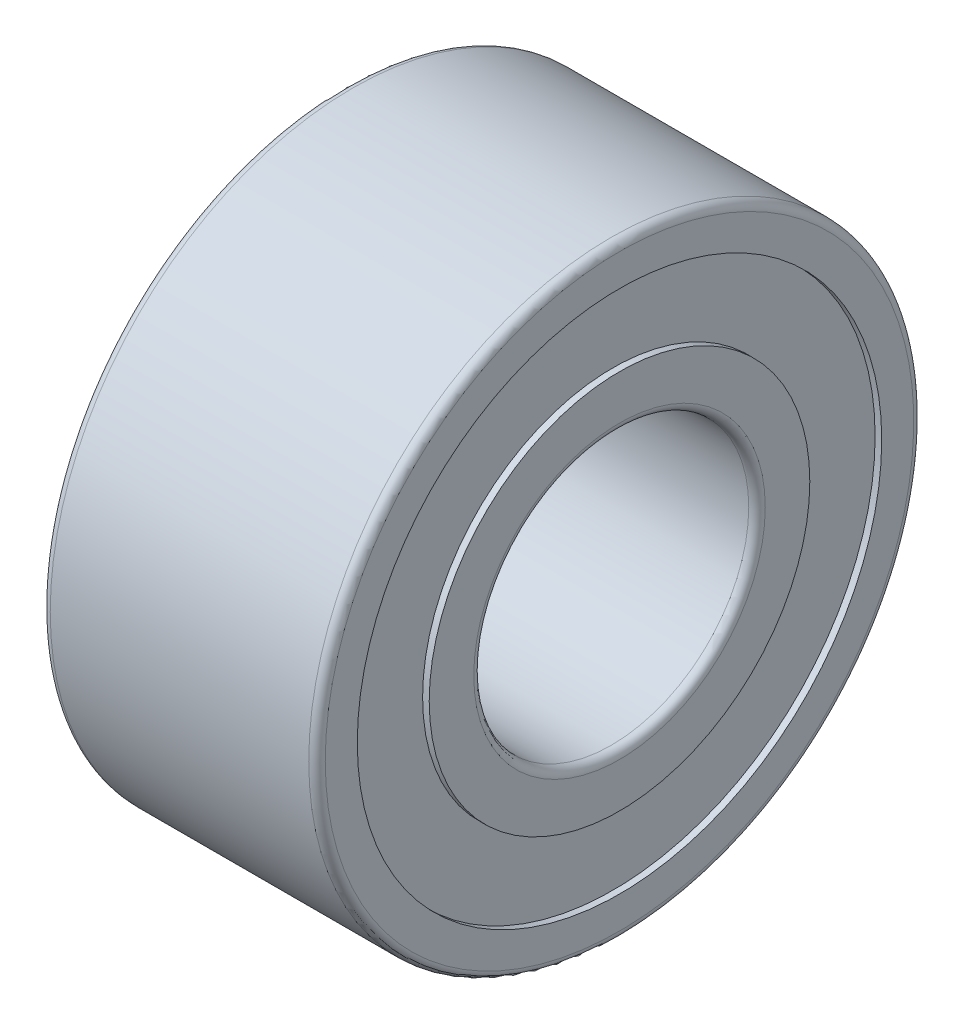
from build123d import *

# Parameters (mm, degrees)
FILLET1_R = 0.15
FILLET2_R = 0.15


with BuildPart() as part:
    # Sketch1 → Revolve1 (revolve)
    with BuildSketch(Plane.XY):
        Polygon((0, 2.5), (5, 2.5), (5, 3.46), (4.88, 3.46), (4.88, 4.7675), (5, 4.7675), (5, 5.5), (0, 5.5), (0, 4.7675), (0.12, 4.7675), (0.12, 3.46), (0, 3.46), align=None)
    revolve(axis=Axis((0, 0, 0), (1, 0, 0)))

    # Fillet1
    fillet1_edges = [part.edges().sort_by_distance(p)[0] for p in [
        (0, -5.5, 0),
        (5, -5.5, 0),
    ]]
    fillet(fillet1_edges, radius=FILLET1_R)

    # Fillet2
    fillet2_edges = [part.edges().sort_by_distance(p)[0] for p in [
        (5, -2.5, 0),
        (0, -2.5, 0),
    ]]
    fillet(fillet2_edges, radius=FILLET2_R)


solid = part.part
